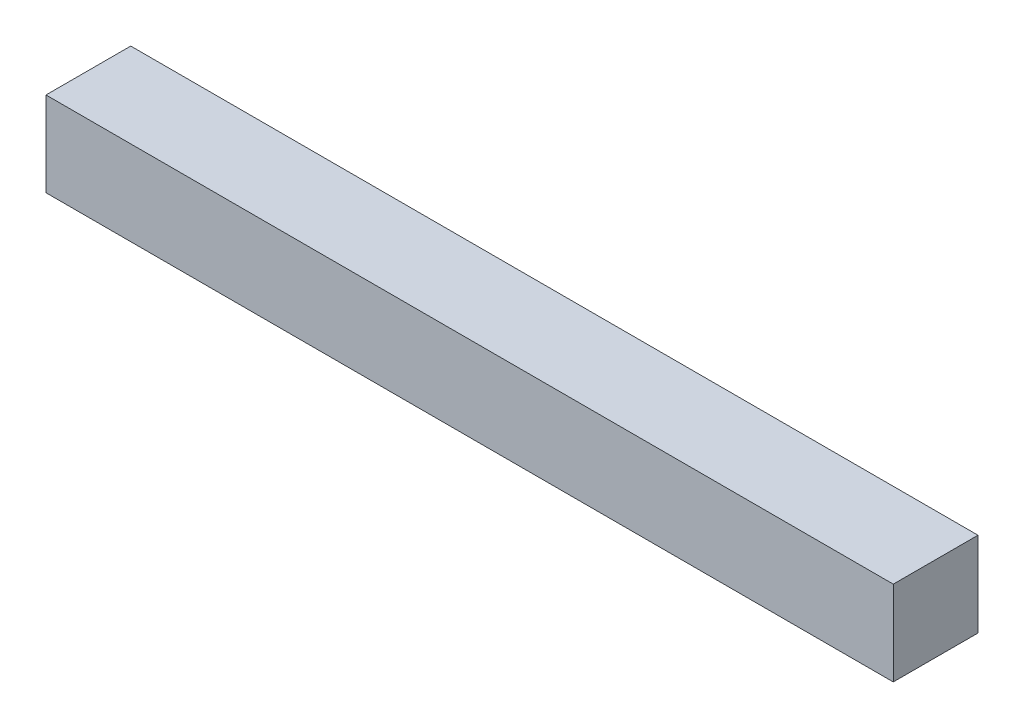
from build123d import *

# Parameters (mm, degrees)
ESQUISSE1_W             = 300
ESQUISSE1_H             = 30
BOSS_EXTRU_4_DEPTH      = 30
ESQUISSE3_R             = 6
ENL_V_MAT_EXTRU_1_DEPTH = 10


with BuildPart() as part:
    # Esquisse1 → Boss.-Extru.4 (new body)
    with BuildSketch(Plane.XY):
        with Locations((81.373258024, 0.3515625)):
            Rectangle(ESQUISSE1_W, ESQUISSE1_H)
    extrude(amount=BOSS_EXTRU_4_DEPTH)

    # Esquisse3 → Enlèv. mat.-Extru.1 (cut)
    with BuildSketch(Plane.XY):
        with Locations((-53.626741976, 0.3515625)):
            Circle(ESQUISSE3_R)
        with Locations((-23.626741976, 0.3515625)):
            Circle(ESQUISSE3_R)
        with Locations((6.373258024, 0.3515625)):
            Circle(ESQUISSE3_R)
        with Locations((36.373258024, 0.3515625)):
            Circle(ESQUISSE3_R)
        with Locations((66.373258024, 0.3515625)):
            Circle(ESQUISSE3_R)
        with Locations((96.373258024, 0.3515625)):
            Circle(ESQUISSE3_R)
        with Locations((126.373258024, 0.3515625)):
            Circle(ESQUISSE3_R)
        with Locations((156.373258024, 0.3515625)):
            Circle(ESQUISSE3_R)
        with Locations((186.373258024, 0.3515625)):
            Circle(ESQUISSE3_R)
        with Locations((216.373258024, 0.3515625)):
            Circle(ESQUISSE3_R)
    extrude(amount=ENL_V_MAT_EXTRU_1_DEPTH, mode=Mode.SUBTRACT)


solid = part.part
